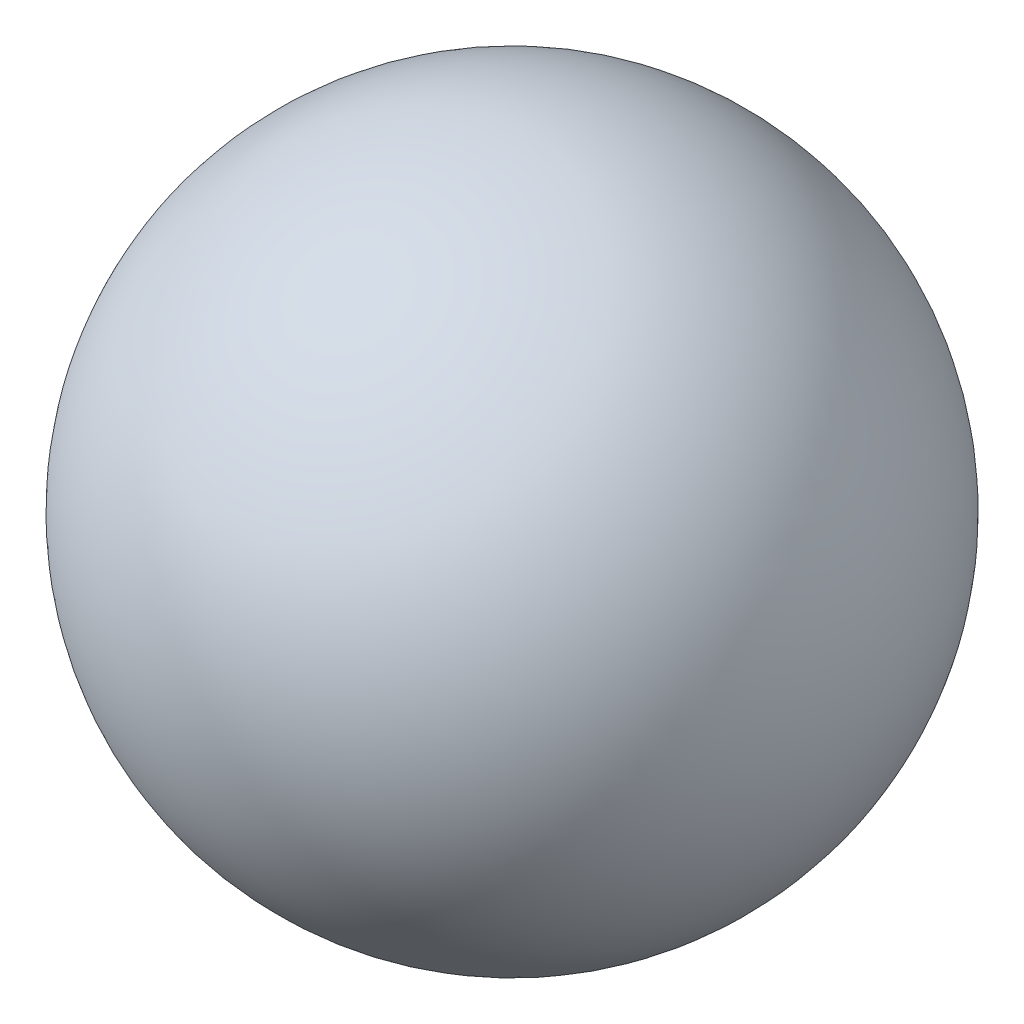
from build123d import *


with BuildPart() as part:
    # Sketch1 one side → Revolve1 (revolve)
    with BuildSketch(Plane.XY):
        with BuildLine():
            ThreePointArc((-22.225, 0), (0, -22.225), (22.225, 0))
            Line((22.225, 0), (0, 0))
            Line((0, 0), (-22.225, 0))
        make_face()
    revolve(axis=Axis((22.225, 0, 0), (-1, 0, 0)))


solid = part.part
